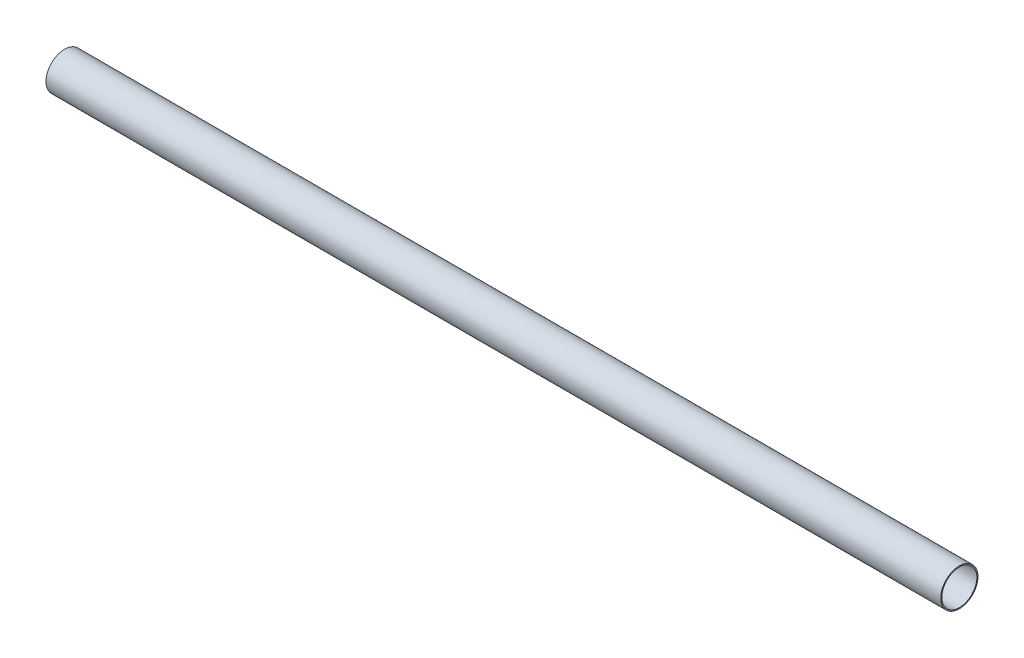
from build123d import *

# Parameters (mm, degrees)
SKETCH1_R      = 20.6375
SKETCH1_R_2    = 19.3929
EXTRUDE1_DEPTH = 495.3


with BuildPart() as part:
    # Sketch1 → Extrude1 (new body, symmetric)
    with BuildSketch(Plane(origin=(0, 0, 0), x_dir=(0, 0, -1), z_dir=(1, 0, 0))):
        Circle(SKETCH1_R)
        Circle(SKETCH1_R_2, mode=Mode.SUBTRACT)
    extrude(amount=EXTRUDE1_DEPTH, both=True)


solid = part.part
